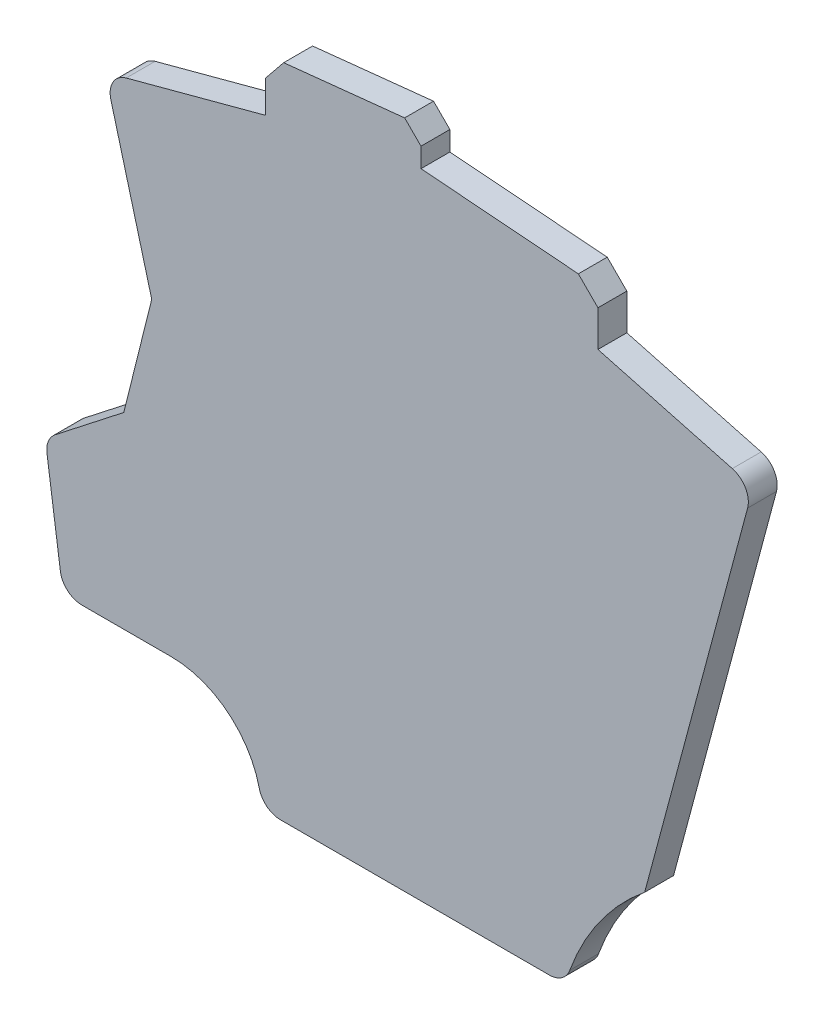
from build123d import *

# Parameters (mm, degrees)
BOSS_EXTRUDE2_DEPTH   = 4
FILLET3_R             = 3
CHAMFER1_SIZE2        = 2.5
CHAMFER1_SIZE         = 2.808402332
CHAMFER1_EDGE_2_SIZE2 = 2.5
CHAMFER1_EDGE_2_SIZE  = 2.275013623
CHAMFER1_EDGE_3_SIZE2 = 2.5
CHAMFER1_EDGE_3_SIZE  = 2.72195283


with BuildPart() as part:
    # Sketch1 → Boss-Extrude2 (new body)
    with BuildSketch(Plane.XY):
        with BuildLine():
            ThreePointArc((-159.244638184, -33.673282531), (-150.584384146, -37.159404343), (-146.754642187, -45.673282531))
            Line((-146.754642187, -45.673282531), (-104.73463418, -45.673282531))
            ThreePointArc((-104.73463418, -45.673282531), (-100.473058927, -36.575080639), (-93.705391257, -29.149653001))
            Line((-93.705391257, -29.149653001), (-78.674501487, 26.946391303))
            Line((-78.674501487, 26.946391303), (-100.174501487, 32.70729894))
            Line((-100.174501487, 32.70729894), (-100.174501487, 40.20729894))
            Line((-100.174501487, 40.20729894), (-124.674501487, 42.135490757))
            Line((-124.674501487, 42.135490757), (-124.674501487, 47.335490757))
            Line((-124.674501487, 47.335490757), (-146.174501487, 45.079555506))
            Line((-146.174501487, 45.079555506), (-146.174501487, 37.779555506))
            Line((-146.174501487, 37.779555506), (-168.390795492, 31.826717469))
            Line((-168.390795492, 31.826717469), (-161.960014873, 7.826717469))
            Line((-161.960014873, 7.826717469), (-165.824598917, -7.673282531))
            Line((-165.824598917, -7.673282531), (-176.704102791, -16.173282531))
            Line((-176.704102791, -16.173282531), (-174.244638184, -33.673282531))
            Line((-174.244638184, -33.673282531), (-159.244638184, -33.673282531))
        make_face()
    extrude(amount=BOSS_EXTRUDE2_DEPTH)

    # Fillet3
    fillet3_edges = [part.edges().sort_by_distance(p)[0] for p in [
        (-104.73463418, -45.673282531, 2),
        (-146.754642187, -45.673282531, 2),
        (-174.244638184, -33.673282531, 2),
        (-176.704102791, -16.173282531, 2),
        (-168.390795492, 31.826717469, 2),
        (-78.674501487, 26.946391303, 2),
    ]]
    fillet(fillet3_edges, radius=FILLET3_R)

    # Chamfer1
    chamfer1_edges = [part.edges().sort_by_distance(p)[0] for p in [
        (-146.174501487, 45.079555506, 2),
    ]]
    chamfer(chamfer1_edges, length=CHAMFER1_SIZE, length2=CHAMFER1_SIZE2)

    # Chamfer1 edge 2
    chamfer1_edge_2_edges = [part.edges().sort_by_distance(p)[0] for p in [
        (-124.674501487, 47.335490757, 2),
    ]]
    chamfer(chamfer1_edge_2_edges, length=CHAMFER1_EDGE_2_SIZE, length2=CHAMFER1_EDGE_2_SIZE2)

    # Chamfer1 edge 3
    chamfer1_edge_3_edges = [part.edges().sort_by_distance(p)[0] for p in [
        (-100.174501487, 40.20729894, 2),
    ]]
    chamfer(chamfer1_edge_3_edges, length=CHAMFER1_EDGE_3_SIZE, length2=CHAMFER1_EDGE_3_SIZE2)


solid = part.part
